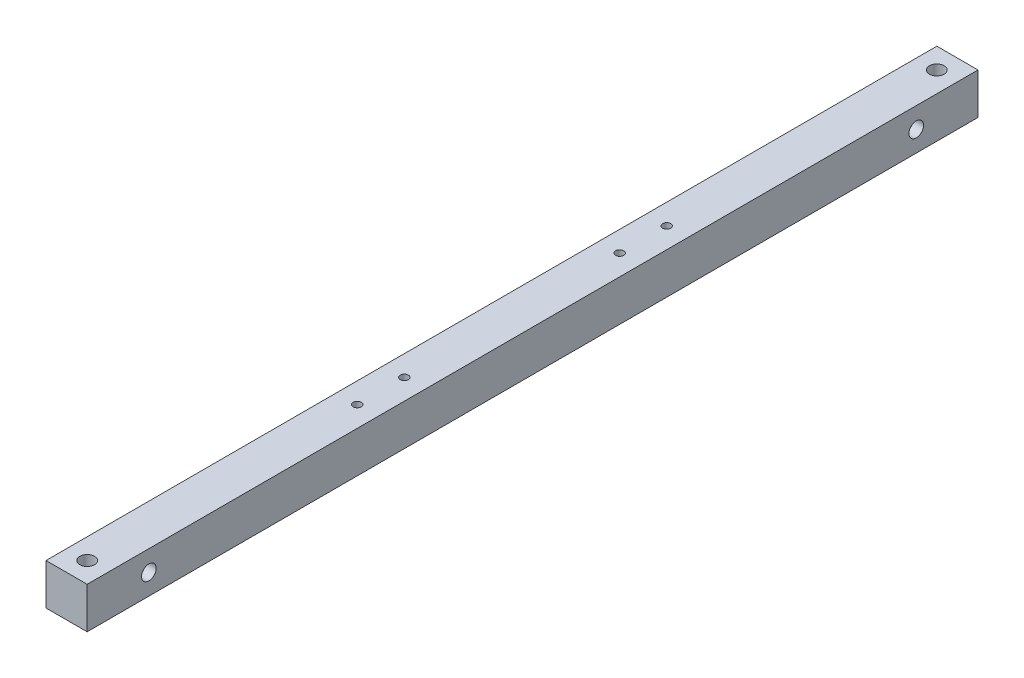
from build123d import *

# Parameters (mm, degrees)
IZIM1_W                     = 28
IZIM1_H                     = 28
Y_KSEKLIK_EKSTR_ZYON1_DEPTH = 606
IZIM2_R                     = 5
KES_EKSTR_ZYON1_DEPTH       = 7
IZIM3_R                     = 3
KES_EKSTR_ZYON2_DEPTH       = 1
KES_EKSTR_ZYON2_DEPTH_BACK  = 29
KES_EKSTR_ZYON3_REACH       = 30
IZIM4_R                     = 3
IZIM6_R                     = 5
KES_EKSTR_ZYON5_DEPTH       = 7
IZIM7_R                     = 2.75
KES_EKSTR_ZYON6_DEPTH       = 29


with BuildPart() as part:
    # Çizim1 → Yükseklik-Ekstrüzyon1 (new body)
    with BuildSketch(Plane.XY):
        Rectangle(IZIM1_W, IZIM1_H)
    extrude(amount=Y_KSEKLIK_EKSTR_ZYON1_DEPTH)

    # Çizim2 → Kes-Ekstrüzyon1 (cut)
    with BuildSketch(Plane(origin=(14, 0, 0), x_dir=(0, 0, -1), z_dir=(1, 0, 0))):
        with Locations((-564, 0)):
            Circle(IZIM2_R)
        with Locations((-42, 0)):
            Circle(IZIM2_R)
    extrude(amount=-KES_EKSTR_ZYON1_DEPTH, mode=Mode.SUBTRACT)

    # Çizim3 → Kes-Ekstrüzyon2 (cut, two sides)
    with BuildSketch(Plane(origin=(14, 0, 0), x_dir=(0, 0, -1), z_dir=(1, 0, 0))) as kes_ekstr_zyon2_sk:
        with Locations((-564, 0)):
            Circle(IZIM3_R)
        with Locations((-42, 0)):
            Circle(IZIM3_R)
    extrude(amount=KES_EKSTR_ZYON2_DEPTH, mode=Mode.SUBTRACT)
    extrude(kes_ekstr_zyon2_sk.sketch, amount=-KES_EKSTR_ZYON2_DEPTH_BACK, mode=Mode.SUBTRACT)

    # Çizim4 → Kes-Ekstrüzyon3 (cut, up to next)
    with BuildSketch(Plane.XZ.offset(14), mode=Mode.PRIVATE) as kes_ekstr_zyon3_sk1:
        with Locations((0, 14)):
            Circle(IZIM4_R)
    kes_ekstr_zyon3_tool1 = extrude(kes_ekstr_zyon3_sk1.sketch, amount=-KES_EKSTR_ZYON3_REACH, mode=Mode.PRIVATE) & part.part
    add(kes_ekstr_zyon3_tool1.solids().sort_by_distance((0, -14, 14))[0], mode=Mode.SUBTRACT)
    # Çizim4 → Kes-Ekstrüzyon3 (cut, up to next)
    with BuildSketch(Plane.XZ.offset(14), mode=Mode.PRIVATE) as kes_ekstr_zyon3_sk2:
        with Locations((0, 592)):
            Circle(IZIM4_R)
    kes_ekstr_zyon3_tool2 = extrude(kes_ekstr_zyon3_sk2.sketch, amount=-KES_EKSTR_ZYON3_REACH, mode=Mode.PRIVATE) & part.part
    add(kes_ekstr_zyon3_tool2.solids().sort_by_distance((0, -14, 592))[0], mode=Mode.SUBTRACT)

    # Çizim6 → Kes-Ekstrüzyon5 (cut)
    with BuildSketch(Plane(origin=(0, 14, 0), x_dir=(1, 0, 0), z_dir=(0, 1, 0))):
        with Locations((0, -592)):
            Circle(IZIM6_R)
        with Locations((0, -14)):
            Circle(IZIM6_R)
    extrude(amount=-KES_EKSTR_ZYON5_DEPTH, mode=Mode.SUBTRACT)

    # Çizim7 → Kes-Ekstrüzyon6 (cut, through all)
    with BuildSketch(Plane(origin=(0, 14, 0), x_dir=(1, 0, 0), z_dir=(0, 1, 0))):
        with Locations((0, -408.25)):
            Circle(IZIM7_R)
        with Locations((0, -376.25)):
            Circle(IZIM7_R)
        with Locations((0, -229.75)):
            Circle(IZIM7_R)
        with Locations((0, -197.75)):
            Circle(IZIM7_R)
    extrude(amount=-KES_EKSTR_ZYON6_DEPTH, mode=Mode.SUBTRACT)


solid = part.part
